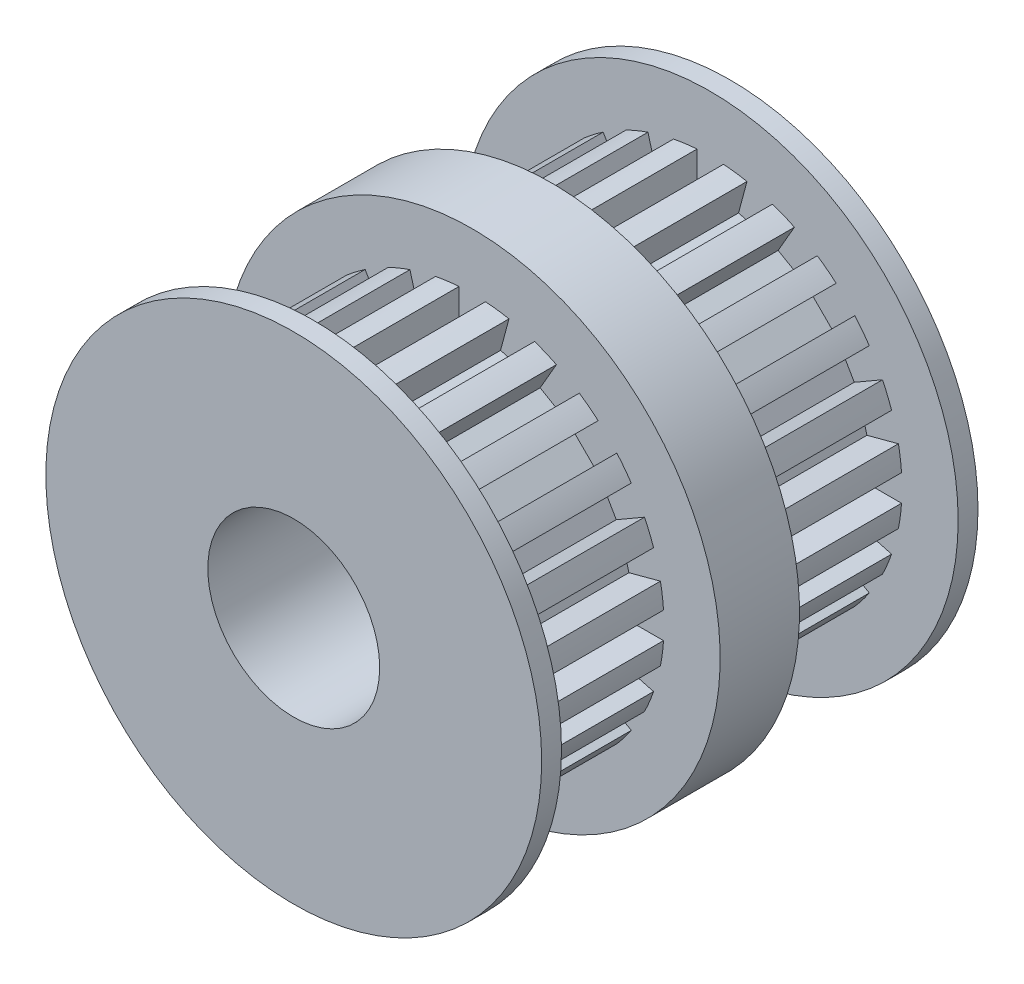
from build123d import *
from build123d.topology import SkipClean

# Parameters (mm, degrees)
SKETCH1_R                = 9.525
BOSS_EXTRUDE1_DEPTH      = 0.762
SKETCH2_R                = 7.366
BOSS_EXTRUDE2_DEPTH      = 6.096
SKETCH3_R                = 9.525
BOSS_EXTRUDE3_DEPTH      = 5.334
SKETCH4_R                = 3.302
CUT_EXTRUDE1_DEPTH       = 57.912
SKETCH5_W                = 6.096
SKETCH5_H                = 1.016
CUT_EXTRUDE2_DEPTH       = 1.27
CIRPATTERN1_COUNT        = 24
CUT_EXTRUDE3_DEPTH       = 152.4
CUT_EXTRUDE3_DEPTH_BACK  = 152.4
SKETCH6_W                = 19.05
SKETCH6_H                = 3.81
SKETCH7_R                = 9.525
BOSS_EXTRUDE4_DEPTH      = 1.524
MIRROR8_COPY_1_SKETCH_W  = 6.096
MIRROR8_COPY_1_SKETCH_H  = 1.016
MIRROR8_COPY_1_DEPTH     = 1.27
MIRROR8_COPY_2_SKETCH_W  = 6.096
MIRROR8_COPY_2_SKETCH_H  = 1.016
MIRROR8_COPY_2_DEPTH     = 1.27
MIRROR8_COPY_3_SKETCH_W  = 6.096
MIRROR8_COPY_3_SKETCH_H  = 1.016
MIRROR8_COPY_3_DEPTH     = 1.27
MIRROR8_COPY_4_SKETCH_W  = 6.096
MIRROR8_COPY_4_SKETCH_H  = 1.016
MIRROR8_COPY_4_DEPTH     = 1.27
MIRROR8_COPY_5_SKETCH_W  = 6.096
MIRROR8_COPY_5_SKETCH_H  = 1.016
MIRROR8_COPY_5_DEPTH     = 1.27
MIRROR8_COPY_6_SKETCH_W  = 6.096
MIRROR8_COPY_6_SKETCH_H  = 1.016
MIRROR8_COPY_6_DEPTH     = 1.27
MIRROR8_COPY_7_SKETCH_W  = 6.096
MIRROR8_COPY_7_SKETCH_H  = 1.016
MIRROR8_COPY_7_DEPTH     = 1.27
MIRROR8_COPY_8_SKETCH_W  = 6.096
MIRROR8_COPY_8_SKETCH_H  = 1.016
MIRROR8_COPY_8_DEPTH     = 1.27
MIRROR8_COPY_9_SKETCH_W  = 6.096
MIRROR8_COPY_9_SKETCH_H  = 1.016
MIRROR8_COPY_9_DEPTH     = 1.27
MIRROR8_COPY_10_SKETCH_W = 6.096
MIRROR8_COPY_10_SKETCH_H = 1.016
MIRROR8_COPY_10_DEPTH    = 1.27
MIRROR8_COPY_11_SKETCH_W = 6.096
MIRROR8_COPY_11_SKETCH_H = 1.016
MIRROR8_COPY_11_DEPTH    = 1.27
MIRROR8_COPY_12_SKETCH_W = 6.096
MIRROR8_COPY_12_SKETCH_H = 1.016
MIRROR8_COPY_12_DEPTH    = 1.27
MIRROR8_COPY_13_SKETCH_W = 6.096
MIRROR8_COPY_13_SKETCH_H = 1.016
MIRROR8_COPY_13_DEPTH    = 1.27
MIRROR8_COPY_14_SKETCH_W = 6.096
MIRROR8_COPY_14_SKETCH_H = 1.016
MIRROR8_COPY_14_DEPTH    = 1.27
MIRROR8_COPY_15_SKETCH_W = 6.096
MIRROR8_COPY_15_SKETCH_H = 1.016
MIRROR8_COPY_15_DEPTH    = 1.27
MIRROR8_COPY_16_SKETCH_W = 6.096
MIRROR8_COPY_16_SKETCH_H = 1.016
MIRROR8_COPY_16_DEPTH    = 1.27
MIRROR8_COPY_17_SKETCH_W = 6.096
MIRROR8_COPY_17_SKETCH_H = 1.016
MIRROR8_COPY_17_DEPTH    = 1.27
MIRROR8_COPY_18_SKETCH_W = 6.096
MIRROR8_COPY_18_SKETCH_H = 1.016
MIRROR8_COPY_18_DEPTH    = 1.27
MIRROR8_COPY_19_SKETCH_W = 6.096
MIRROR8_COPY_19_SKETCH_H = 1.016
MIRROR8_COPY_19_DEPTH    = 1.27
MIRROR8_COPY_20_SKETCH_W = 6.096
MIRROR8_COPY_20_SKETCH_H = 1.016
MIRROR8_COPY_20_DEPTH    = 1.27
MIRROR8_COPY_21_SKETCH_W = 6.096
MIRROR8_COPY_21_SKETCH_H = 1.016
MIRROR8_COPY_21_DEPTH    = 1.27
MIRROR8_COPY_22_SKETCH_W = 6.096
MIRROR8_COPY_22_SKETCH_H = 1.016
MIRROR8_COPY_22_DEPTH    = 1.27
MIRROR8_COPY_23_SKETCH_W = 6.096
MIRROR8_COPY_23_SKETCH_H = 1.016
MIRROR8_COPY_23_DEPTH    = 1.27
MIRROR8_COPY_24_SKETCH_W = 6.096
MIRROR8_COPY_24_SKETCH_H = 1.016
MIRROR8_COPY_24_DEPTH    = 1.27
CUT_EXTRUDE4_START       = -22.098
SKETCH8_R                = 3.302
CUT_EXTRUDE4_DEPTH       = 22.098


with BuildPart() as part:
    # Sketch1 → Boss-Extrude1 (new body)
    with BuildSketch(Plane.XY):
        Circle(SKETCH1_R)
    boss_extrude1 = extrude(amount=-BOSS_EXTRUDE1_DEPTH)

    # Sketch2 → Boss-Extrude2 (add)
    with BuildSketch(Plane(origin=(0, 0, -0.762), x_dir=(-1, 0, 0), z_dir=(0, 0, -1))):
        Circle(SKETCH2_R)
    boss_extrude2 = extrude(amount=BOSS_EXTRUDE2_DEPTH)

    # Sketch3 → Boss-Extrude3 (add)
    with BuildSketch(Plane(origin=(0, 0, -6.858), x_dir=(-1, 0, 0), z_dir=(0, 0, -1))):
        Circle(SKETCH3_R)
    extrude(amount=BOSS_EXTRUDE3_DEPTH)

    # Sketch4 → Cut-Extrude1 (cut)
    with BuildSketch(Plane.XY):
        Circle(SKETCH4_R)
    extrude(amount=-CUT_EXTRUDE1_DEPTH, mode=Mode.SUBTRACT)

    # Sketch5 → Cut-Extrude2 (cut)
    with BuildSketch(Plane.ZY.offset(7.366)):
        with Locations((-3.81, 0)):
            Rectangle(SKETCH5_W, SKETCH5_H)
    cut_extrude2 = extrude(amount=-CUT_EXTRUDE2_DEPTH, mode=Mode.SUBTRACT)

    # CirPattern1: Cut-Extrude2 ×24 about axis
    cirpattern1_axis = Axis((0, 0, -12.192), (0, 0, 1))
    for i in range(1, CIRPATTERN1_COUNT):
        add(cut_extrude2.rotate(cirpattern1_axis, i * 360 / CIRPATTERN1_COUNT), mode=Mode.SUBTRACT)

    # Sketch6 → Cut-Extrude3 (cut, two sides: drawn at the far end of the back side and taken through both)
    with BuildSketch(Plane(origin=(0, 0, 0), x_dir=(1, 0, 0), z_dir=(0, 1, 0)).offset(-CUT_EXTRUDE3_DEPTH_BACK)):
        with Locations((0, 10.287)):
            Rectangle(SKETCH6_W, SKETCH6_H)
    extrude(amount=CUT_EXTRUDE3_DEPTH + CUT_EXTRUDE3_DEPTH_BACK, mode=Mode.SUBTRACT)

    # Sketch7 → Boss-Extrude4 (add)
    with BuildSketch(Plane(origin=(0, 0, -8.382), x_dir=(-1, 0, 0), z_dir=(0, 0, -1))):
        Circle(SKETCH7_R)
    extrude(amount=BOSS_EXTRUDE4_DEPTH)

    # Mirror7: Boss-Extrude2 across plane
    add(boss_extrude2.mirror(Plane(origin=(0, 0, -8.382), x_dir=(1, 0, 0), z_dir=(0, 0, -1))))

    # Mirror8 copy 1 sketch → Mirror8 copy 1 (cut)
    with BuildSketch(Plane(origin=(-7.115009636, -1.906461086, -16.764), x_dir=(0, 0, -1), z_dir=(-0.9659258262890683, -0.25881904510252074, 0))):
        with Locations((-3.81, 0)):
            Rectangle(MIRROR8_COPY_1_SKETCH_W, MIRROR8_COPY_1_SKETCH_H)
    extrude(amount=-MIRROR8_COPY_1_DEPTH, mode=Mode.SUBTRACT)

    # Mirror8 copy 2 sketch → Mirror8 copy 2 (cut)
    with BuildSketch(Plane(origin=(-6.379143124, -3.683, -16.764), x_dir=(0, 0, -1), z_dir=(-0.8660254037844387, -0.49999999999999994, 0))):
        with Locations((-3.81, 0)):
            Rectangle(MIRROR8_COPY_2_SKETCH_W, MIRROR8_COPY_2_SKETCH_H)
    extrude(amount=-MIRROR8_COPY_2_DEPTH, mode=Mode.SUBTRACT)

    # Mirror8 copy 3 sketch → Mirror8 copy 3 (cut)
    with BuildSketch(Plane(origin=(-5.20854855, -5.20854855, -16.764), x_dir=(0, 0, -1), z_dir=(-0.7071067811865476, -0.7071067811865475, 0))):
        with Locations((-3.81, 0)):
            Rectangle(MIRROR8_COPY_3_SKETCH_W, MIRROR8_COPY_3_SKETCH_H)
    extrude(amount=-MIRROR8_COPY_3_DEPTH, mode=Mode.SUBTRACT)

    # Mirror8 copy 4 sketch → Mirror8 copy 4 (cut)
    with BuildSketch(Plane(origin=(-3.683, -6.379143124, -16.764), x_dir=(0, 0, -1), z_dir=(-0.5000000000000001, -0.8660254037844386, 0))):
        with Locations((-3.81, 0)):
            Rectangle(MIRROR8_COPY_4_SKETCH_W, MIRROR8_COPY_4_SKETCH_H)
    extrude(amount=-MIRROR8_COPY_4_DEPTH, mode=Mode.SUBTRACT)

    # Mirror8 copy 5 sketch → Mirror8 copy 5 (cut)
    with BuildSketch(Plane(origin=(-1.906461086, -7.115009636, -16.764), x_dir=(0, 0, -1), z_dir=(-0.25881904510252074, -0.9659258262890683, 0))):
        with Locations((-3.81, 0)):
            Rectangle(MIRROR8_COPY_5_SKETCH_W, MIRROR8_COPY_5_SKETCH_H)
    extrude(amount=-MIRROR8_COPY_5_DEPTH, mode=Mode.SUBTRACT)

    # Mirror8 copy 6 sketch → Mirror8 copy 6 (cut)
    with BuildSketch(Plane(origin=(0, -7.366, -16.764), x_dir=(0, 0, -1), z_dir=(0, -1, 0))):
        with Locations((-3.81, 0)):
            Rectangle(MIRROR8_COPY_6_SKETCH_W, MIRROR8_COPY_6_SKETCH_H)
    extrude(amount=-MIRROR8_COPY_6_DEPTH, mode=Mode.SUBTRACT)

    # Mirror8 copy 7 sketch → Mirror8 copy 7 (cut)
    with BuildSketch(Plane(origin=(1.906461086, -7.115009636, -16.764), x_dir=(0, 0, -1), z_dir=(0.25881904510252085, -0.9659258262890683, 0))):
        with Locations((-3.81, 0)):
            Rectangle(MIRROR8_COPY_7_SKETCH_W, MIRROR8_COPY_7_SKETCH_H)
    extrude(amount=-MIRROR8_COPY_7_DEPTH, mode=Mode.SUBTRACT)

    # Mirror8 copy 8 sketch → Mirror8 copy 8 (cut)
    with BuildSketch(Plane(origin=(3.683, -6.379143124, -16.764), x_dir=(0, 0, -1), z_dir=(0.4999999999999998, -0.8660254037844387, 0))):
        with Locations((-3.81, 0)):
            Rectangle(MIRROR8_COPY_8_SKETCH_W, MIRROR8_COPY_8_SKETCH_H)
    extrude(amount=-MIRROR8_COPY_8_DEPTH, mode=Mode.SUBTRACT)

    # Mirror8 copy 9 sketch → Mirror8 copy 9 (cut)
    with BuildSketch(Plane(origin=(5.20854855, -5.20854855, -16.764), x_dir=(0, 0, -1), z_dir=(0.7071067811865475, -0.7071067811865476, 0))):
        with Locations((-3.81, 0)):
            Rectangle(MIRROR8_COPY_9_SKETCH_W, MIRROR8_COPY_9_SKETCH_H)
    extrude(amount=-MIRROR8_COPY_9_DEPTH, mode=Mode.SUBTRACT)

    # Mirror8 copy 10 sketch → Mirror8 copy 10 (cut)
    with BuildSketch(Plane(origin=(6.379143124, -3.683, -16.764), x_dir=(0, 0, -1), z_dir=(0.8660254037844387, -0.49999999999999994, 0))):
        with Locations((-3.81, 0)):
            Rectangle(MIRROR8_COPY_10_SKETCH_W, MIRROR8_COPY_10_SKETCH_H)
    extrude(amount=-MIRROR8_COPY_10_DEPTH, mode=Mode.SUBTRACT)

    # Mirror8 copy 11 sketch → Mirror8 copy 11 (cut)
    with BuildSketch(Plane(origin=(7.115009636, -1.906461086, -16.764), x_dir=(0, 0, -1), z_dir=(0.9659258262890682, -0.258819045102521, 0))):
        with Locations((-3.81, 0)):
            Rectangle(MIRROR8_COPY_11_SKETCH_W, MIRROR8_COPY_11_SKETCH_H)
    extrude(amount=-MIRROR8_COPY_11_DEPTH, mode=Mode.SUBTRACT)

    # Mirror8 copy 12 sketch → Mirror8 copy 12 (cut)
    with BuildSketch(Plane(origin=(7.366, 0, -16.764), x_dir=(0, 0, -1), z_dir=(1, 0, 0))):
        with Locations((-3.81, 0)):
            Rectangle(MIRROR8_COPY_12_SKETCH_W, MIRROR8_COPY_12_SKETCH_H)
    extrude(amount=-MIRROR8_COPY_12_DEPTH, mode=Mode.SUBTRACT)

    # Mirror8 copy 13 sketch → Mirror8 copy 13 (cut)
    with BuildSketch(Plane(origin=(7.115009636, 1.906461086, -16.764), x_dir=(0, 0, -1), z_dir=(0.9659258262890683, 0.2588190451025208, 0))):
        with Locations((-3.81, 0)):
            Rectangle(MIRROR8_COPY_13_SKETCH_W, MIRROR8_COPY_13_SKETCH_H)
    extrude(amount=-MIRROR8_COPY_13_DEPTH, mode=Mode.SUBTRACT)

    # Mirror8 copy 14 sketch → Mirror8 copy 14 (cut)
    with BuildSketch(Plane(origin=(6.379143124, 3.683, -16.764), x_dir=(0, 0, -1), z_dir=(0.8660254037844386, 0.5000000000000001, 0))):
        with Locations((-3.81, 0)):
            Rectangle(MIRROR8_COPY_14_SKETCH_W, MIRROR8_COPY_14_SKETCH_H)
    extrude(amount=-MIRROR8_COPY_14_DEPTH, mode=Mode.SUBTRACT)

    # Mirror8 copy 15 sketch → Mirror8 copy 15 (cut)
    with BuildSketch(Plane(origin=(5.20854855, 5.20854855, -16.764), x_dir=(0, 0, -1), z_dir=(0.7071067811865477, 0.7071067811865475, 0))):
        with Locations((-3.81, 0)):
            Rectangle(MIRROR8_COPY_15_SKETCH_W, MIRROR8_COPY_15_SKETCH_H)
    extrude(amount=-MIRROR8_COPY_15_DEPTH, mode=Mode.SUBTRACT)

    # Mirror8 copy 16 sketch → Mirror8 copy 16 (cut)
    with BuildSketch(Plane(origin=(3.683, 6.379143124, -16.764), x_dir=(0, 0, -1), z_dir=(0.5000000000000004, 0.8660254037844384, 0))):
        with Locations((-3.81, 0)):
            Rectangle(MIRROR8_COPY_16_SKETCH_W, MIRROR8_COPY_16_SKETCH_H)
    extrude(amount=-MIRROR8_COPY_16_DEPTH, mode=Mode.SUBTRACT)

    # Mirror8 copy 17 sketch → Mirror8 copy 17 (cut)
    with BuildSketch(Plane(origin=(1.906461086, 7.115009636, -16.764), x_dir=(0, 0, -1), z_dir=(0.25881904510252063, 0.9659258262890683, 0))):
        with Locations((-3.81, 0)):
            Rectangle(MIRROR8_COPY_17_SKETCH_W, MIRROR8_COPY_17_SKETCH_H)
    extrude(amount=-MIRROR8_COPY_17_DEPTH, mode=Mode.SUBTRACT)

    # Mirror8 copy 18 sketch → Mirror8 copy 18 (cut)
    with BuildSketch(Plane(origin=(0, 7.366, -16.764), x_dir=(0, 0, -1), z_dir=(0, 1, 0))):
        with Locations((-3.81, 0)):
            Rectangle(MIRROR8_COPY_18_SKETCH_W, MIRROR8_COPY_18_SKETCH_H)
    extrude(amount=-MIRROR8_COPY_18_DEPTH, mode=Mode.SUBTRACT)

    # Mirror8 copy 19 sketch → Mirror8 copy 19 (cut)
    with BuildSketch(Plane(origin=(-1.906461086, 7.115009636, -16.764), x_dir=(0, 0, -1), z_dir=(-0.2588190451025203, 0.9659258262890684, 0))):
        with Locations((-3.81, 0)):
            Rectangle(MIRROR8_COPY_19_SKETCH_W, MIRROR8_COPY_19_SKETCH_H)
    extrude(amount=-MIRROR8_COPY_19_DEPTH, mode=Mode.SUBTRACT)

    # Mirror8 copy 20 sketch → Mirror8 copy 20 (cut)
    with BuildSketch(Plane(origin=(-3.683, 6.379143124, -16.764), x_dir=(0, 0, -1), z_dir=(-0.5000000000000001, 0.8660254037844386, 0))):
        with Locations((-3.81, 0)):
            Rectangle(MIRROR8_COPY_20_SKETCH_W, MIRROR8_COPY_20_SKETCH_H)
    extrude(amount=-MIRROR8_COPY_20_DEPTH, mode=Mode.SUBTRACT)

    # Mirror8 copy 21 sketch → Mirror8 copy 21 (cut)
    with BuildSketch(Plane(origin=(-5.20854855, 5.20854855, -16.764), x_dir=(0, 0, -1), z_dir=(-0.7071067811865474, 0.7071067811865477, 0))):
        with Locations((-3.81, 0)):
            Rectangle(MIRROR8_COPY_21_SKETCH_W, MIRROR8_COPY_21_SKETCH_H)
    extrude(amount=-MIRROR8_COPY_21_DEPTH, mode=Mode.SUBTRACT)

    # Mirror8 copy 22 sketch → Mirror8 copy 22 (cut)
    with BuildSketch(Plane(origin=(-6.379143124, 3.683, -16.764), x_dir=(0, 0, -1), z_dir=(-0.8660254037844384, 0.5000000000000004, 0))):
        with Locations((-3.81, 0)):
            Rectangle(MIRROR8_COPY_22_SKETCH_W, MIRROR8_COPY_22_SKETCH_H)
    extrude(amount=-MIRROR8_COPY_22_DEPTH, mode=Mode.SUBTRACT)

    # Mirror8 copy 23 sketch → Mirror8 copy 23 (cut)
    with BuildSketch(Plane(origin=(-7.115009636, 1.906461086, -16.764), x_dir=(0, 0, -1), z_dir=(-0.9659258262890683, 0.2588190451025207, 0))):
        with Locations((-3.81, 0)):
            Rectangle(MIRROR8_COPY_23_SKETCH_W, MIRROR8_COPY_23_SKETCH_H)
    extrude(amount=-MIRROR8_COPY_23_DEPTH, mode=Mode.SUBTRACT)

    # Mirror8 copy 24 sketch → Mirror8 copy 24 (cut)
    with BuildSketch(Plane(origin=(-7.366, 0, -16.764), x_dir=(0, 0, -1), z_dir=(-1, 0, 0))):
        with Locations((-3.81, 0)):
            Rectangle(MIRROR8_COPY_24_SKETCH_W, MIRROR8_COPY_24_SKETCH_H)
    extrude(amount=-MIRROR8_COPY_24_DEPTH, mode=Mode.SUBTRACT)

    # Mirror9: Boss-Extrude1 across plane
    add(boss_extrude1.mirror(Plane(origin=(0, 0, -8.382), x_dir=(1, 0, 0), z_dir=(0, 0, -1))))

    # Sketch8 → Cut-Extrude4 (cut)
    with SkipClean():  # the faces are left unmerged after this step: merging them gives an invalid solid
        with BuildSketch(Plane(origin=(0, 0, -16.764), x_dir=(-1, 0, 0), z_dir=(0, 0, -1)).offset(CUT_EXTRUDE4_START)):
            Circle(SKETCH8_R)
        extrude(amount=CUT_EXTRUDE4_DEPTH, mode=Mode.SUBTRACT)


solid = part.part
